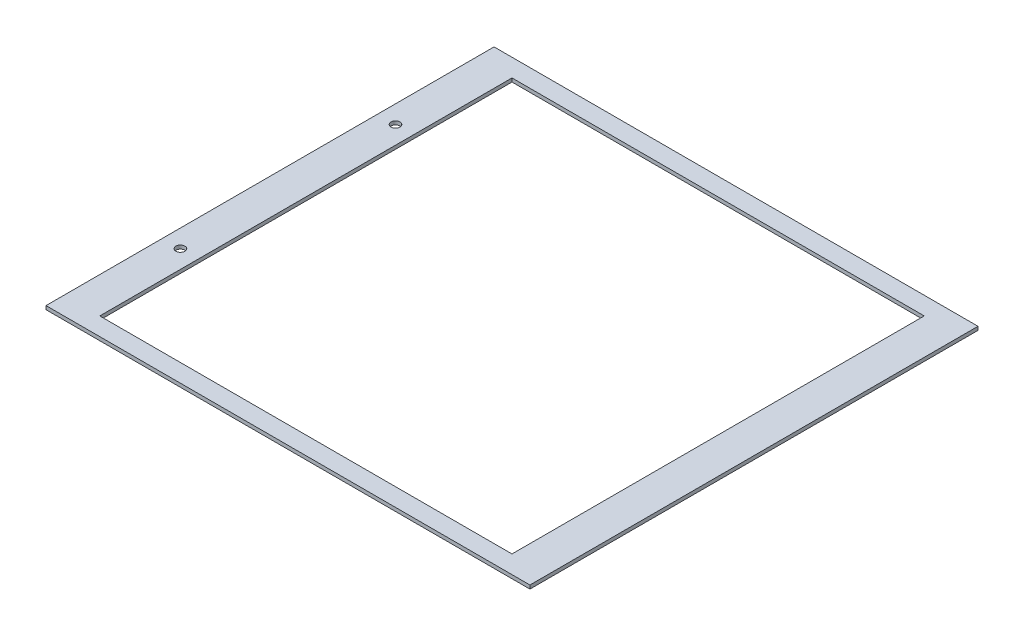
from build123d import *

# Parameters (mm, degrees)
SKETCH_1_W          = 270
SKETCH_1_H          = 250
SKETCH_1_W_2        = 230
SKETCH_1_H_2        = 230
EXTRUDE_1_DEPTH     = 2
SKETCH_2_R          = 2.5
CUT_EXTRUDE_1_DEPTH = 3


with BuildPart() as part:
    # Эскиз1 → Бобышка-Вытянуть1 (new body)
    with BuildSketch(Plane(origin=(0, 0, 0), x_dir=(1, 0, 0), z_dir=(0, 1, 0))):
        Rectangle(SKETCH_1_W, SKETCH_1_H)
        Rectangle(SKETCH_1_W_2, SKETCH_1_H_2, mode=Mode.SUBTRACT)
    extrude(amount=EXTRUDE_1_DEPTH)

    # Эскиз2 → Вырез-Вытянуть1 (cut, through all)
    with BuildSketch(Plane(origin=(0, 2, 0), x_dir=(1, 0, 0), z_dir=(0, 1, 0))):
        with Locations((-125, 60)):
            Circle(SKETCH_2_R)
        with Locations((-125, -60)):
            Circle(SKETCH_2_R)
    extrude(amount=-CUT_EXTRUDE_1_DEPTH, mode=Mode.SUBTRACT)


solid = part.part
